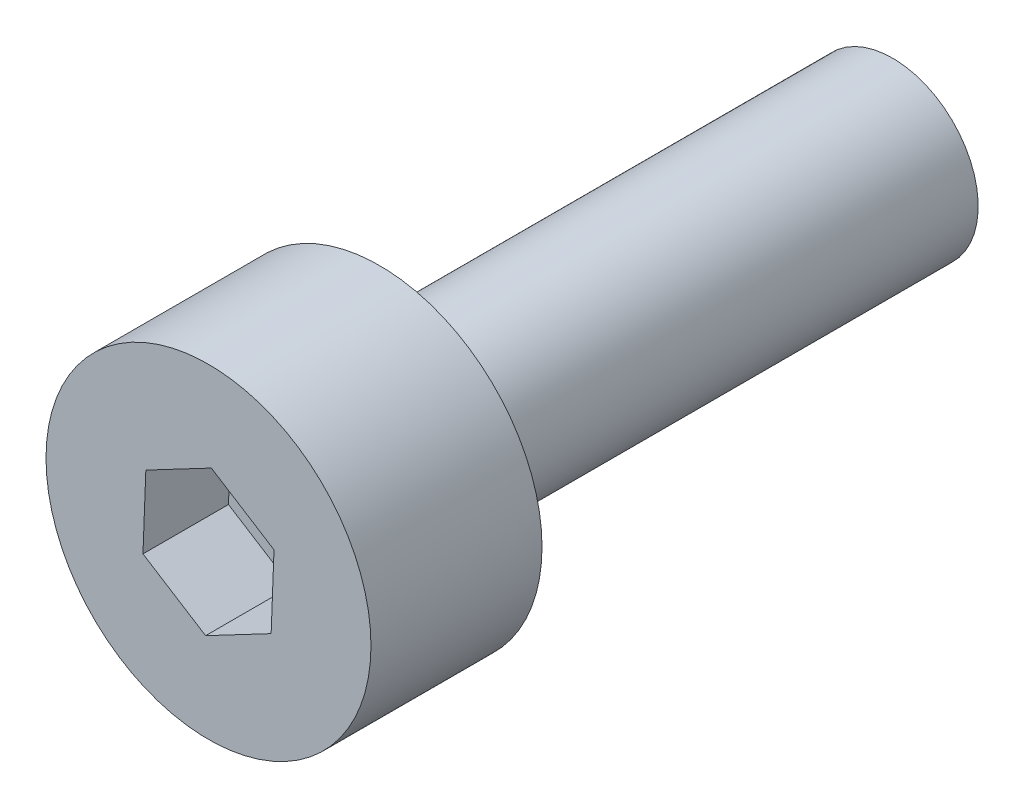
from build123d import *

# Parameters (mm, degrees)
SKETCH_1_R          = 1.9
EXTRUDE_1_DEPTH     = 2
SKETCH_2_R          = 1
EXTRUDE_2_DEPTH     = 6
CUT_EXTRUDE_1_DEPTH = 1


with BuildPart() as part:
    # 草图1 → 凸台-拉伸1 (new body)
    with BuildSketch(Plane.XY):
        Circle(SKETCH_1_R)
    extrude(amount=EXTRUDE_1_DEPTH)

    # 草图2 → 凸台-拉伸2 (add)
    with BuildSketch(Plane(origin=(0, 0, 0), x_dir=(-1, 0, 0), z_dir=(0, 0, -1))):
        Circle(SKETCH_2_R)
    extrude(amount=EXTRUDE_2_DEPTH)

    # 草图3 → 切除-拉伸1 (cut)
    with BuildSketch(Plane.XY.offset(2)):
        Polygon((-0.766222709, -0.403612141), (-0.033572987, -0.865374401), (0.732649722, -0.461762261), (0.766222709, 0.403612141), (0.033572987, 0.865374401), (-0.732649722, 0.461762261), align=None)
    extrude(amount=-CUT_EXTRUDE_1_DEPTH, mode=Mode.SUBTRACT)


solid = part.part
